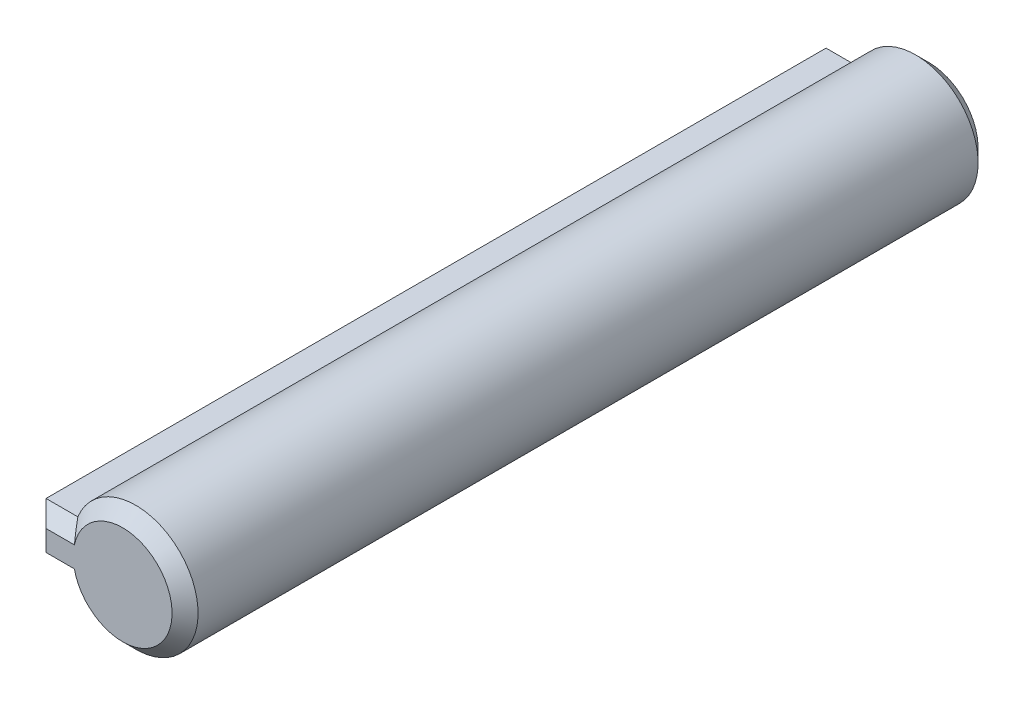
from build123d import *

# Parameters (mm, degrees)
BOSS_EXTRUDE1_DEPTH = 62
CHAMFER1_SIZE       = 1
CHAMFER2_SIZE       = 1
SCALE1_SCALE        = 0.75
SCALE2_SCALE        = 0.85


with BuildPart() as part:
    # Sketch1 → Boss-Extrude1 (new body)
    with BuildSketch(Plane(origin=(0, 0, 0), x_dir=(0, 1, 0), z_dir=(0, 0, 1))):
        with BuildLine():
            Line((1.8, 6.897570975), (-1.8, 6.897570975))
            Line((-1.8, 6.897570975), (-1.8, 4.449719092))
            ThreePointArc((-1.8, 4.449719092), (0, 4.8), (1.8, 4.449719092))
            Line((1.8, 4.449719092), (1.8, 6.897570975))
        make_face()
        with BuildLine():
            ThreePointArc((1.8, 4.449719092), (0, 4.8), (-1.8, 4.449719092))
            Line((-1.8, 4.449719092), (-1.8, 1.697570975))
            Line((-1.8, 1.697570975), (1.8, 1.697570975))
            Line((1.8, 1.697570975), (1.8, 4.449719092))
        make_face()
        with BuildLine():
            Line((-1.8, 1.697570975), (-1.8, 4.449719092))
            ThreePointArc((-1.8, 4.449719092), (-2.683281573, -3.979949748), (4.8, 0))
            ThreePointArc((4.8, 0), (3.979949748, 2.683281573), (1.8, 4.449719092))
            Line((1.8, 4.449719092), (1.8, 1.697570975))
            Line((1.8, 1.697570975), (-1.8, 1.697570975))
        make_face()
    extrude(amount=BOSS_EXTRUDE1_DEPTH)

    # Chamfer1
    chamfer1_edges = [part.edges().sort_by_distance(p)[0] for p in [
        (3.979949748, -2.683281573, 62),
        (-5.673645034, 1.8, 62),
        (-6.897570975, 0, 62),
        (-5.673645034, -1.8, 62),
    ]]
    chamfer(chamfer1_edges, length=CHAMFER1_SIZE)

    # Chamfer2
    chamfer2_edges = [part.edges().sort_by_distance(p)[0] for p in [
        (-6.897570975, 0, 0),
        (-5.673645034, 1.8, 0),
        (3.979949748, -2.683281573, 0),
        (-5.673645034, -1.8, 0),
    ]]
    chamfer(chamfer2_edges, length=CHAMFER2_SIZE)


with BuildPart() as part_1:
    # Scale1: scaled about (-0.57130559, 0, 31)
    add(part.part.scale(SCALE1_SCALE).moved(Location((-0.142826398, 0, 7.75))))


with BuildPart() as part_2:
    # Scale2: scaled about (-0.57130559, 0, 31)
    add(part_1.part.scale(SCALE2_SCALE).moved(Location((-0.085695839, 0, 4.65))))


solid = part_2.part
